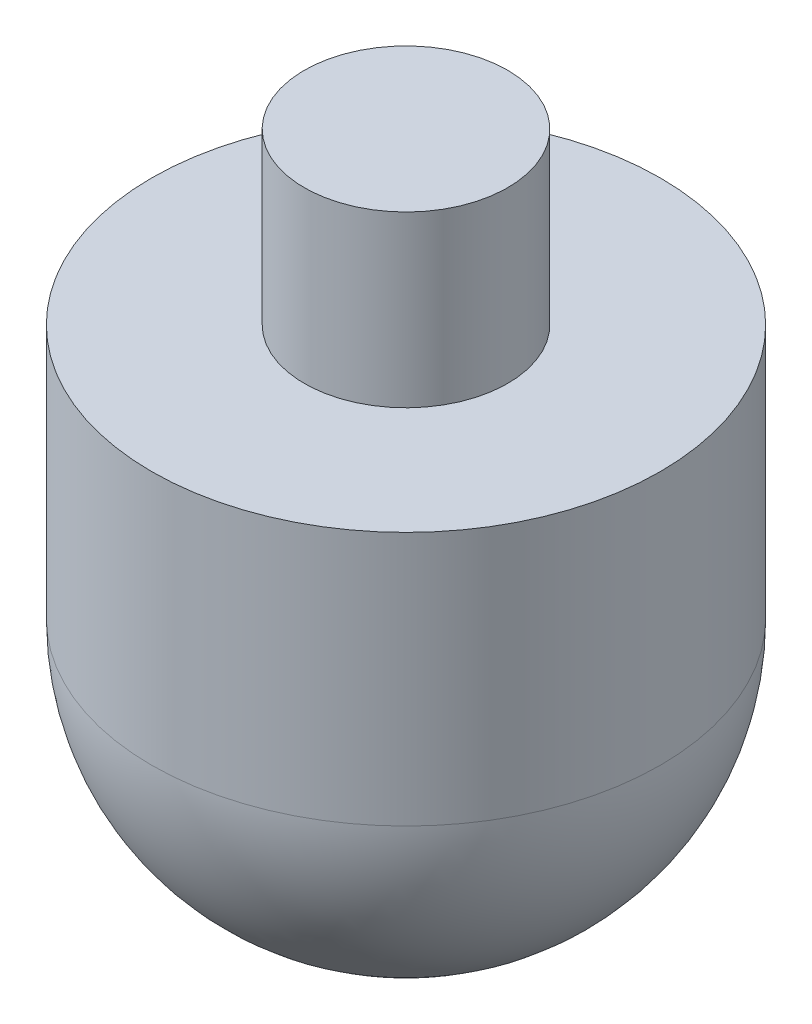
from build123d import *


with BuildPart() as part:
    # Croquis1 → Revolución1 (revolve)
    with BuildSketch(Plane.XY):
        with BuildLine():
            Line((0, 40), (6, 40))
            Line((6, 40), (6, 30))
            Line((6, 30), (15, 30))
            Line((15, 30), (15, 15))
            ThreePointArc((15, 15), (10.606601718, 4.393398282), (0, 0))
            Line((0, 0), (0, 40))
        make_face()
    revolve(axis=Axis((0, 0, 0), (0, 1, 0)))


solid = part.part
